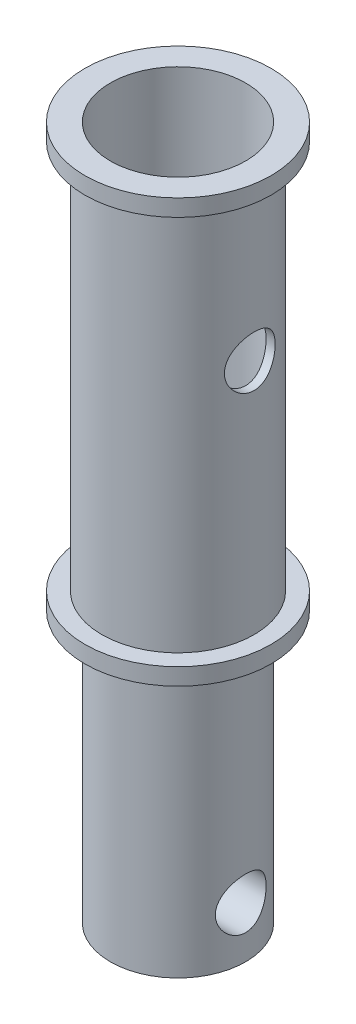
from build123d import *

# Parameters (mm, degrees)
SKETCH1_R           = 5.5
BOSS_EXTRUDE1_DEPTH = 1
SKETCH1_3_R         = 4
BOSS_EXTRUDE2_DEPTH = 16
SKETCH2_R           = 1.5
CUT_EXTRUDE1_DEPTH  = 13
BOSS_EXTRUDE3_START = 25
SKETCH1_4_R         = 4.5
SKETCH1_4_R_2       = 4
BOSS_EXTRUDE3_DEPTH = 25
BOSS_EXTRUDE4_START = 24
SKETCH1_5_R         = 5.5
SKETCH1_5_R_2       = 4.5
BOSS_EXTRUDE4_DEPTH = 1
SKETCH5_R           = 1.5
CUT_EXTRUDE2_DEPTH  = 11.5


with BuildPart() as part:
    # Sketch1 → Boss-Extrude1 (new body)
    with BuildSketch(Plane(origin=(0, 0, 0), x_dir=(1, 0, 0), z_dir=(0, 1, 0))):
        Circle(SKETCH1_R)
    extrude(amount=BOSS_EXTRUDE1_DEPTH)

    # Sketch1_3 → Boss-Extrude2 (add)
    with BuildSketch(Plane(origin=(0, 0, 0), x_dir=(1, 0, 0), z_dir=(0, 1, 0))):
        Circle(SKETCH1_3_R)
    extrude(amount=-BOSS_EXTRUDE2_DEPTH)

    # Sketch2 → Cut-Extrude1 (cut)
    with BuildSketch(Plane(origin=(4, 0, 0), x_dir=(0, 0, -1), z_dir=(1, 0, 0))):
        with Locations((0, -13)):
            Circle(SKETCH2_R)
    extrude(amount=-CUT_EXTRUDE1_DEPTH, mode=Mode.SUBTRACT)

    # Sketch1_4 → Boss-Extrude3 (add)
    with BuildSketch(Plane(origin=(0, 0, 0), x_dir=(1, 0, 0), z_dir=(0, 1, 0)).offset(BOSS_EXTRUDE3_START)):
        Circle(SKETCH1_4_R)
        Circle(SKETCH1_4_R_2, mode=Mode.SUBTRACT)
    extrude(amount=-BOSS_EXTRUDE3_DEPTH)

    # Sketch1_5 → Boss-Extrude4 (add)
    with BuildSketch(Plane(origin=(0, 0, 0), x_dir=(1, 0, 0), z_dir=(0, 1, 0)).offset(BOSS_EXTRUDE4_START)):
        Circle(SKETCH1_5_R)
        Circle(SKETCH1_5_R_2, mode=Mode.SUBTRACT)
    extrude(amount=BOSS_EXTRUDE4_DEPTH)

    # Sketch5 → Cut-Extrude2 (cut, symmetric)
    with BuildSketch(Plane(origin=(4, 0, 0), x_dir=(0, 0, -1), z_dir=(1, 0, 0))):
        with Locations((0, 15)):
            Circle(SKETCH5_R)
    extrude(amount=CUT_EXTRUDE2_DEPTH, both=True, mode=Mode.SUBTRACT)


solid = part.part
